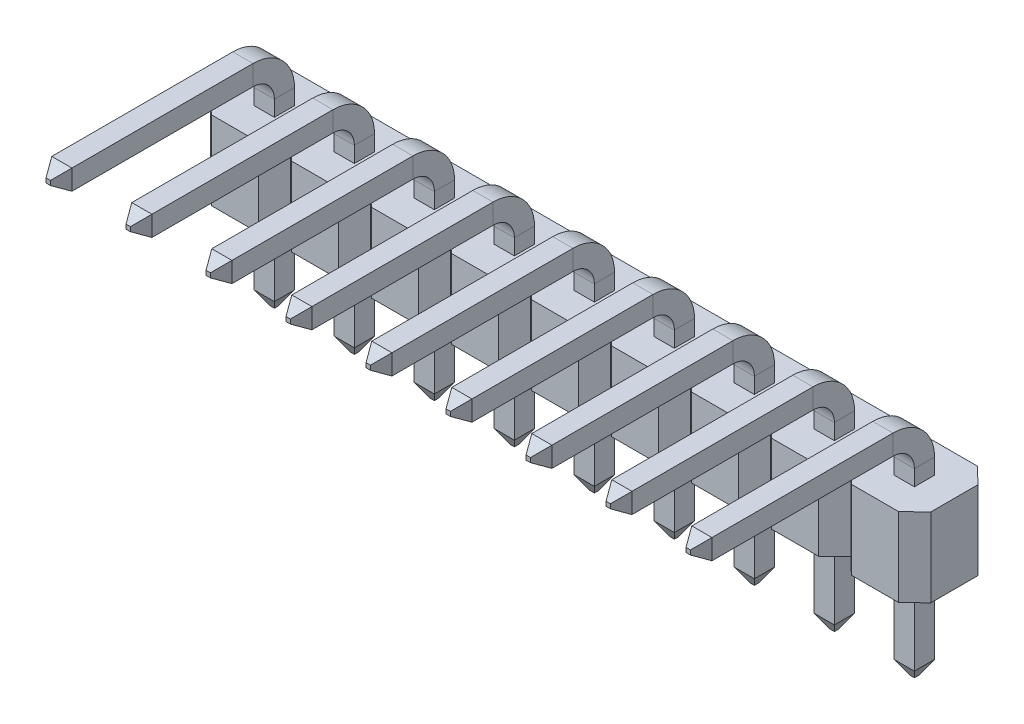
from build123d import *

# Parameters (mm, degrees)
SKETCH1_W                     = 2.54
SKETCH1_H                     = 2.5
SKETCH1_W_2                   = 0.64
SKETCH1_H_2                   = 0.64
PLASTIC_CONNECTION_BODY_DEPTH = 2.5
CORNERS_TRIMMED_DEPTH         = 2.5
SKETCH4_W                     = 0.64
SKETCH4_H                     = 0.64
BENT_PIN_CHAMFER_1_SIZE       = 0.25
BENT_PIN_CHAMFER_1_SIZE2      = 0.433012702
BENT_PIN_CHAMFER_2_SIZE       = 0.25
BENT_PIN_CHAMFER_2_SIZE2      = 0.433012702
SKETCH6_R                     = 0.5
CUT_EXTRUDE1_DEPTH            = 0.1
LPATTERN_1_COUNT              = 5
LPATTERN_1_PITCH              = 2.54
LPATTERN_1_2_COUNT            = 5
LPATTERN_1_2_PITCH            = 2.54


with BuildPart() as part:
    # Sketch1 → Plastic Connection Body (new body)
    with BuildSketch(Plane(origin=(0, 0, 0), x_dir=(1, 0, 0), z_dir=(0, 1, 0))):
        Rectangle(SKETCH1_W, SKETCH1_H)
        Rectangle(SKETCH1_W_2, SKETCH1_H_2, mode=Mode.SUBTRACT)
    extrude(amount=PLASTIC_CONNECTION_BODY_DEPTH)

    # Sketch3 → Corners Trimmed (cut)
    with BuildSketch(Plane(origin=(0, 2.5, 0), x_dir=(1, 0, 0), z_dir=(0, 1, 0))):
        Polygon((-0.75, 1.25), (-1.27, 0.75), (-1.27, 1.25), align=None)
        Polygon((0.75, 1.25), (1.27, 0.75), (1.27, 1.25), align=None)
        Polygon((-1.27, -0.75), (-1.27, -1.25), (-0.75, -1.25), align=None)
        Polygon((0.75, -1.25), (1.27, -0.75), (1.27, -1.25), align=None)
    extrude(amount=-CORNERS_TRIMMED_DEPTH, mode=Mode.SUBTRACT)

    # Sketch6 → Cut-Extrude1 (cut)
    with BuildSketch(Plane.XZ):
        Circle(SKETCH6_R)
    extrude(amount=-CUT_EXTRUDE1_DEPTH, mode=Mode.SUBTRACT)


with BuildPart() as body_2:
    # Sweep-1 Bent Pin: sweep along a path in Sketch5
    with BuildLine(Plane(origin=(0, 0, 0), x_dir=(0, 0, -1), z_dir=(1, 0, 0))) as sweep_1_bent_pin_path:
        Line((0, -3), (0, 3))
        ThreePointArc((0, 3), (-0.292893219, 3.707106781), (-1, 4))
        Line((-1, 4), (-7.18, 4))
    # Sketch4 → Sweep-1 Bent Pin (sweep)
    with BuildSketch(Plane.XZ):
        Rectangle(SKETCH4_W, SKETCH4_H)
    sweep(path=sweep_1_bent_pin_path.line)

    # Bent Pin Chamfer-1
    bent_pin_chamfer_1_edges = [body_2.edges().sort_by_distance(p)[0] for p in [
        (-0.32, 4, 7.18),
        (0, 4.32, 7.18),
        (0.32, 4, 7.18),
        (0, 3.68, 7.18),
    ]]
    bent_pin_chamfer_1_side = [body_2.faces().sort_by_distance(p)[0] for p in [
        (0, 4, 7.18),
    ]]
    chamfer(bent_pin_chamfer_1_edges, length=BENT_PIN_CHAMFER_1_SIZE, length2=BENT_PIN_CHAMFER_1_SIZE2, reference=bent_pin_chamfer_1_side[0])

    # Bent Pin Chamfer-2
    bent_pin_chamfer_2_edges = [body_2.edges().sort_by_distance(p)[0] for p in [
        (0, -3, 0.32),
        (-0.32, -3, 0),
        (0, -3, -0.32),
        (0.32, -3, 0),
    ]]
    bent_pin_chamfer_2_side = [body_2.faces().sort_by_distance(p)[0] for p in [
        (0, -3, 0),
    ]]
    chamfer(bent_pin_chamfer_2_edges, length=BENT_PIN_CHAMFER_2_SIZE, length2=BENT_PIN_CHAMFER_2_SIZE2, reference=bent_pin_chamfer_2_side[0])


with BuildPart() as lpattern_1_1:
    # LPattern-1: pattern copy
    add(part.part.moved(Location(Vector(1, 0, 0) * (1 * LPATTERN_1_PITCH))))


with BuildPart() as lpattern_1_2:
    # LPattern-1: pattern copy
    add(part.part.moved(Location(Vector(1, 0, 0) * (2 * LPATTERN_1_PITCH))))


with BuildPart() as lpattern_1_3:
    # LPattern-1: pattern copy
    add(part.part.moved(Location(Vector(1, 0, 0) * (3 * LPATTERN_1_PITCH))))


with BuildPart() as lpattern_1_4:
    # LPattern-1: pattern copy
    add(part.part.moved(Location(Vector(1, 0, 0) * (4 * LPATTERN_1_PITCH))))


with BuildPart() as lpattern_1_5:
    # LPattern-1: pattern copy
    add(body_2.part.moved(Location(Vector(1, 0, 0) * (1 * LPATTERN_1_PITCH))))


with BuildPart() as lpattern_1_6:
    # LPattern-1: pattern copy
    add(body_2.part.moved(Location(Vector(1, 0, 0) * (2 * LPATTERN_1_PITCH))))


with BuildPart() as lpattern_1_7:
    # LPattern-1: pattern copy
    add(body_2.part.moved(Location(Vector(1, 0, 0) * (3 * LPATTERN_1_PITCH))))


with BuildPart() as lpattern_1_8:
    # LPattern-1: pattern copy
    add(body_2.part.moved(Location(Vector(1, 0, 0) * (4 * LPATTERN_1_PITCH))))


with BuildPart() as lpattern_1_2_1:
    # LPattern-1 2: pattern copy
    add(part.part.moved(Location(Vector(-1, 0, 0) * (1 * LPATTERN_1_2_PITCH))))


with BuildPart() as lpattern_1_2_2:
    # LPattern-1 2: pattern copy
    add(part.part.moved(Location(Vector(-1, 0, 0) * (2 * LPATTERN_1_2_PITCH))))


with BuildPart() as lpattern_1_2_3:
    # LPattern-1 2: pattern copy
    add(part.part.moved(Location(Vector(-1, 0, 0) * (3 * LPATTERN_1_2_PITCH))))


with BuildPart() as lpattern_1_2_4:
    # LPattern-1 2: pattern copy
    add(part.part.moved(Location(Vector(-1, 0, 0) * (4 * LPATTERN_1_2_PITCH))))


with BuildPart() as lpattern_1_2_5:
    # LPattern-1 2: pattern copy
    add(body_2.part.moved(Location(Vector(-1, 0, 0) * (1 * LPATTERN_1_2_PITCH))))


with BuildPart() as lpattern_1_2_6:
    # LPattern-1 2: pattern copy
    add(body_2.part.moved(Location(Vector(-1, 0, 0) * (2 * LPATTERN_1_2_PITCH))))


with BuildPart() as lpattern_1_2_7:
    # LPattern-1 2: pattern copy
    add(body_2.part.moved(Location(Vector(-1, 0, 0) * (3 * LPATTERN_1_2_PITCH))))


with BuildPart() as lpattern_1_2_8:
    # LPattern-1 2: pattern copy
    add(body_2.part.moved(Location(Vector(-1, 0, 0) * (4 * LPATTERN_1_2_PITCH))))


solid = Compound([part.part, body_2.part, lpattern_1_1.part, lpattern_1_2.part, lpattern_1_3.part, lpattern_1_4.part, lpattern_1_5.part, lpattern_1_6.part, lpattern_1_7.part, lpattern_1_8.part, lpattern_1_2_1.part, lpattern_1_2_2.part, lpattern_1_2_3.part, lpattern_1_2_4.part, lpattern_1_2_5.part, lpattern_1_2_6.part, lpattern_1_2_7.part, lpattern_1_2_8.part])
